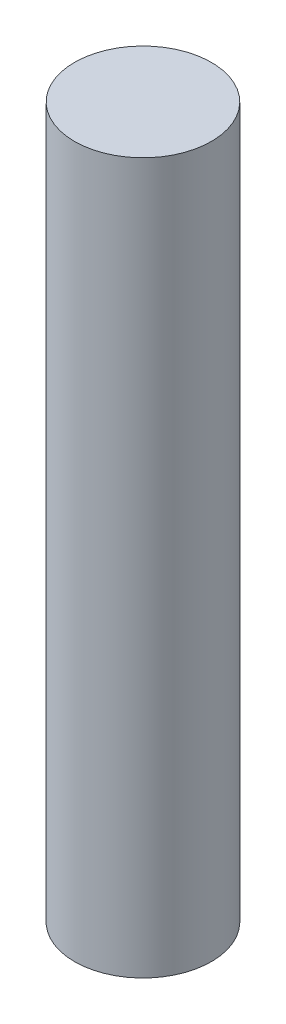
from build123d import *

# Parameters (mm, degrees)
SKETCH1_R      = 4
EXTRUDE1_DEPTH = 41.5


with BuildPart() as part:
    # Sketch1 → Extrude1 (new body)
    with BuildSketch(Plane(origin=(0, 0, 0), x_dir=(1, 0, 0), z_dir=(0, 1, 0))):
        with Locations(Location((0, 0, 0), (0, 0, 270))):  # turned: the seam where the file's is
            Circle(SKETCH1_R)
    extrude(amount=-EXTRUDE1_DEPTH)


solid = part.part
